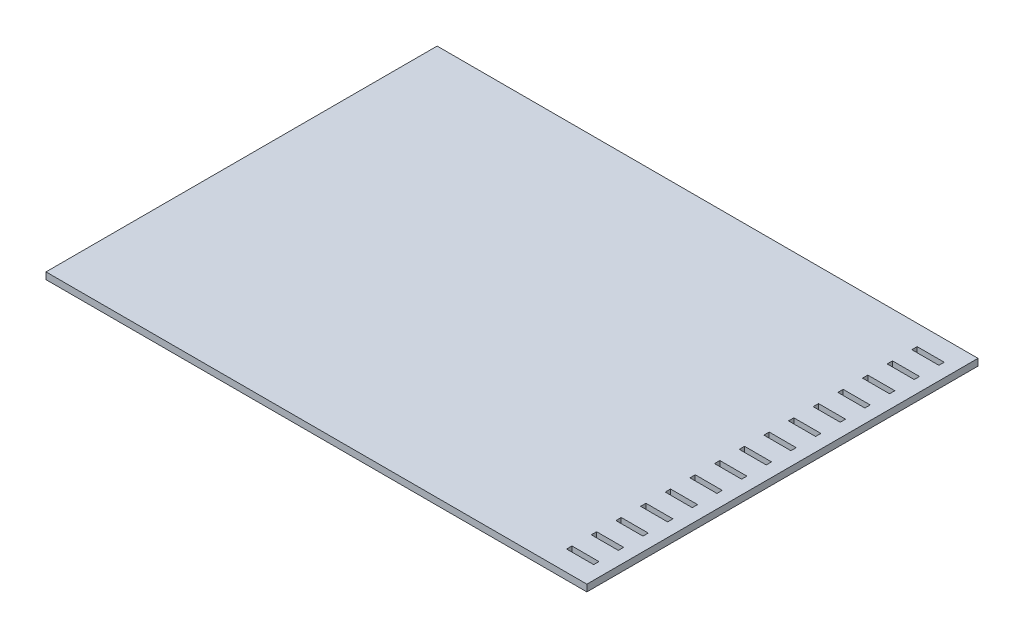
from build123d import *

# Parameters (mm, degrees)
SKETCH1_W           = 203.2
SKETCH1_H           = 146.939
BOSS_EXTRUDE1_DEPTH = 2.54
SKETCH2_W           = 2
SKETCH2_H           = 10.16
CUT_EXTRUDE1_DEPTH  = 2.794
LPATTERN1_COUNT     = 15
LPATTERN1_PITCH     = 9.264214286


with BuildPart() as part:
    # Sketch1 → Boss-Extrude1 (new body)
    with BuildSketch(Plane(origin=(0, 0, 0), x_dir=(1, 0, 0), z_dir=(0, 1, 0))):
        with Locations((35.207920792, -46.991886139)):
            Rectangle(SKETCH1_W, SKETCH1_H)
    extrude(amount=BOSS_EXTRUDE1_DEPTH)

    # Sketch2 → Cut-Extrude1 (cut)
    with BuildSketch(Plane(origin=(0, 2.54, 0), x_dir=(0, 0, -1), z_dir=(0, 1, 0))):
        with Locations((-111.841386139, -126.647920792)):
            Rectangle(SKETCH2_W, SKETCH2_H)
    cut_extrude1 = extrude(amount=-CUT_EXTRUDE1_DEPTH, mode=Mode.SUBTRACT)

    # LPattern1: Cut-Extrude1 ×15
    with Locations(*[(0, 0, -i * LPATTERN1_PITCH) for i in range(1, LPATTERN1_COUNT)]):
        add(cut_extrude1, mode=Mode.SUBTRACT)


solid = part.part
